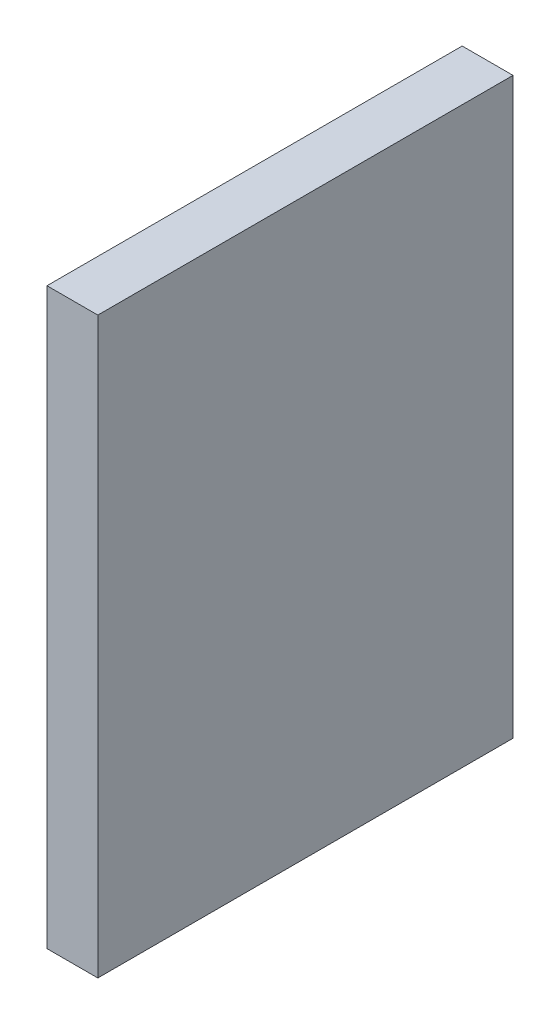
from build123d import *

# Parameters (mm, degrees)
SKETCH1_W           = 24.5
SKETCH1_H           = 33.876964868
BOSS_EXTRUDE1_DEPTH = 3


with BuildPart() as part:
    # Sketch1 → Boss-Extrude1 (new body)
    with BuildSketch(Plane(origin=(0, 0, 0), x_dir=(0, 0, -1), z_dir=(1, 0, 0))):
        with Locations((28.788383019, -39.775181141)):
            Rectangle(SKETCH1_W, SKETCH1_H)
    extrude(amount=BOSS_EXTRUDE1_DEPTH)


solid = part.part
